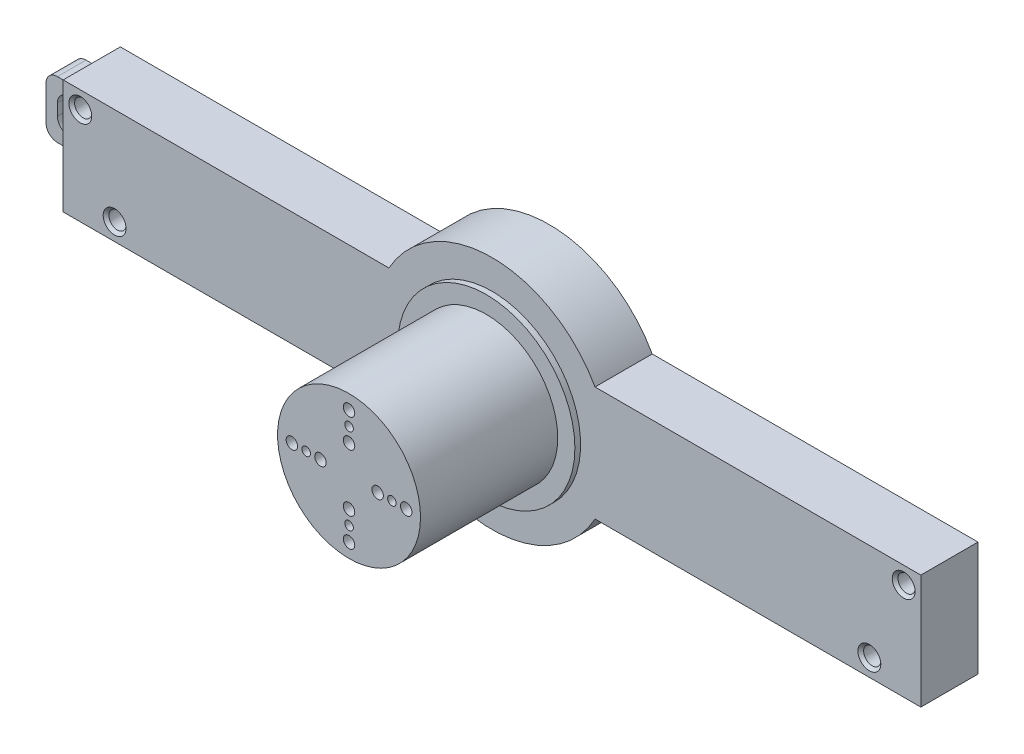
from build123d import *

# Parameters (mm, degrees)
SZKIC1_W                    = 150
SZKIC1_H                    = 20
DODANIE_WYCI_GNI_CIE1_DEPTH = 10
SZKIC2_R                    = 20.61119484
DODANIE_WYCI_GNI_CIE2_DEPTH = 10
SZKIC3_R                    = 12.5
DODANIE_WYCI_GNI_CIE5_DEPTH = 25
SZKIC8_R                    = 15.5
DODANIE_WYCI_GNI_CIE6_DEPTH = 1
SZKIC9_R                    = 1.5
WYTNIJ_WYCI_GNI_CIE1_DEPTH  = 10
SFAZOWANIE1_SIZE            = 0.5
SZKIC10_W                   = 5
SZKIC10_H                   = 10
DODANIE_WYCI_GNI_CIE7_DEPTH = 8
SZKIC11_W                   = 6
SZKIC11_H                   = 6
WYTNIJ_WYCI_GNI_CIE2_DEPTH  = 8
ZAOKR_GLENIE1_R             = 2
SZKIC12_R                   = 1
SZKIC12_R_2                 = 0.75
WYTNIJ_WYCI_GNI_CIE3_DEPTH  = 5


with BuildPart() as part:
    # Szkic1 → Dodanie-wyciągnięcie1 (new body)
    with BuildSketch(Plane.XY):
        Rectangle(SZKIC1_W, SZKIC1_H)
    extrude(amount=DODANIE_WYCI_GNI_CIE1_DEPTH)

    # Szkic2 → Dodanie-wyciągnięcie2 (add)
    with BuildSketch(Plane.XY.offset(10)):
        Circle(SZKIC2_R)
    extrude(amount=-DODANIE_WYCI_GNI_CIE2_DEPTH)

    # Szkic3 → Dodanie-wyciągnięcie5 (add)
    with BuildSketch(Plane.XY.offset(10)):
        Circle(SZKIC3_R)
    extrude(amount=DODANIE_WYCI_GNI_CIE5_DEPTH)

    # Szkic8 → Dodanie-wyciągnięcie6 (add)
    with BuildSketch(Plane.XY.offset(10)):
        Circle(SZKIC8_R)
    extrude(amount=DODANIE_WYCI_GNI_CIE6_DEPTH)

    # Szkic9 → Wytnij-wyciągnięcie1 (cut)
    with BuildSketch(Plane(origin=(0, 0, 0), x_dir=(-1, 0, 0), z_dir=(0, 0, -1))):
        with Locations((-72, 7)):
            Circle(SZKIC9_R)
        with Locations((-66, -7)):
            Circle(SZKIC9_R)
        with Locations((66, -7)):
            Circle(SZKIC9_R)
        with Locations((72, 7)):
            Circle(SZKIC9_R)
    extrude(amount=-WYTNIJ_WYCI_GNI_CIE1_DEPTH, mode=Mode.SUBTRACT)

    # Sfazowanie1
    sfazowanie1_edges = [part.edges().sort_by_distance(p)[0] for p in [
        (73.5, 7, 10),
        (67.5, -7, 10),
        (-64.5, -7, 10),
        (-70.5, 7, 10),
    ]]
    chamfer(sfazowanie1_edges, length=SFAZOWANIE1_SIZE)

    # Szkic10 → Dodanie-wyciągnięcie7 (add)
    with BuildSketch(Plane.ZY.offset(75)):
        with Locations((2.5, 0)):
            Rectangle(SZKIC10_W, SZKIC10_H)
    extrude(amount=DODANIE_WYCI_GNI_CIE7_DEPTH)

    # Szkic11 → Wytnij-wyciągnięcie2 (cut)
    with BuildSketch(Plane(origin=(0, 0, 0), x_dir=(-1, 0, 0), z_dir=(0, 0, -1))):
        with Locations((78, 0)):
            Rectangle(SZKIC11_W, SZKIC11_H)
    extrude(amount=-WYTNIJ_WYCI_GNI_CIE2_DEPTH, mode=Mode.SUBTRACT)

    # Zaokrąglenie1
    zaokr_glenie1_edges = [part.edges().sort_by_distance(p)[0] for p in [
        (-81, 3, 2.5),
        (-81, -3, 2.5),
        (-83, -5, 2.5),
        (-83, 5, 2.5),
    ]]
    fillet(zaokr_glenie1_edges, radius=ZAOKR_GLENIE1_R)

    # Szkic12 → Wytnij-wyciągnięcie3 (cut)
    with BuildSketch(Plane.XY.offset(35)):
        with Locations((-5, 0)):
            Circle(SZKIC12_R)
        with Locations((-10, 0)):
            Circle(SZKIC12_R)
        with Locations((0, 10)):
            Circle(SZKIC12_R)
        with Locations((0, 5)):
            Circle(SZKIC12_R)
        with Locations((10, 0)):
            Circle(SZKIC12_R)
        with Locations((5, 0)):
            Circle(SZKIC12_R)
        with Locations((0, -10)):
            Circle(SZKIC12_R)
        with Locations((0, -5)):
            Circle(SZKIC12_R)
        with Locations((-7.5, 0)):
            Circle(SZKIC12_R_2)
        with Locations((0, 7.5)):
            Circle(SZKIC12_R_2)
        with Locations((7.5, 0)):
            Circle(SZKIC12_R_2)
        with Locations((0, -7.5)):
            Circle(SZKIC12_R_2)
    extrude(amount=-WYTNIJ_WYCI_GNI_CIE3_DEPTH, mode=Mode.SUBTRACT)


solid = part.part
